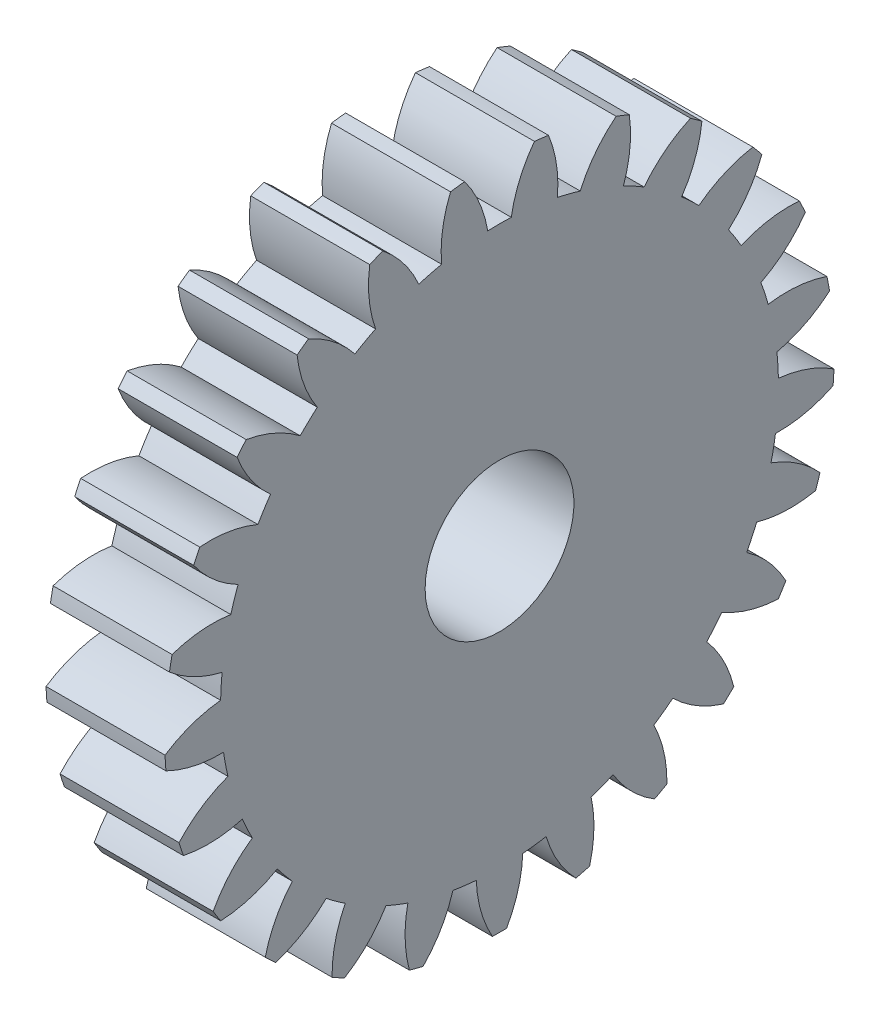
from build123d import *

# Parameters (mm, degrees)
BASPROSKE_W     = 12
BASPROSKE_H     = 33.75
TOOTHCUT_DEPTH  = 50.21508915
TEETHCUTS_COUNT = 25
TEETHCUTS_ANGLE = 345.6
BORSKE_R        = 7.5
BORE_DEPTH      = 50.000508
SCALE2_SCALE    = 0.8


with BuildPart() as part:
    # BasProSke → Base-Revolve (revolve)
    with BuildSketch(Plane(origin=(0, 0, 0), x_dir=(1, 0, 0), z_dir=(0, 1, 0))):
        with Locations((6, 16.875)):
            Rectangle(BASPROSKE_W, BASPROSKE_H)
    revolve(axis=Axis((-10, 0, 0), (1, 0, 0)))

    # TooCutSke → ToothCut (cut, through all)
    with BuildSketch(Plane(origin=(0, 0, 0), x_dir=(0, 0, -1), z_dir=(1, 0, 0))):
        with BuildLine():
            ThreePointArc((1.187856988, 28.098903391), (0, 28.124), (-1.187856988, 28.098903391))
            ThreePointArc((-1.187856988, 28.098903391), (-2.083835169, 31.109603364), (-3.702102288, 33.801870579))
            ThreePointArc((-3.702102288, 33.801870579), (0, 34.004), (3.702102288, 33.801870579))
            ThreePointArc((3.702102288, 33.801870579), (2.083835169, 31.109603364), (1.187856988, 28.098903391))
        make_face()
    toothcut = extrude(amount=TOOTHCUT_DEPTH, mode=Mode.SUBTRACT)

    # TeethCuts: ToothCut ×25 about axis
    teethcuts_axis = Axis((-10, 0, 0), (1, 0, 0))
    for i in range(1, TEETHCUTS_COUNT):
        add(toothcut.rotate(teethcuts_axis, i * TEETHCUTS_ANGLE / (TEETHCUTS_COUNT - 1)), mode=Mode.SUBTRACT)

    # BorSke → Bore (cut, symmetric)
    with BuildSketch(Plane(origin=(0, 0, 0), x_dir=(0, 0, -1), z_dir=(1, 0, 0))):
        Circle(BORSKE_R)
    extrude(amount=BORE_DEPTH, both=True, mode=Mode.SUBTRACT)


with BuildPart() as part_1:
    # Scale2: scaled about (6, 0, 0)
    add(part.part.scale(SCALE2_SCALE).moved(Location((1.2, 0, 0))))


solid = part_1.part
